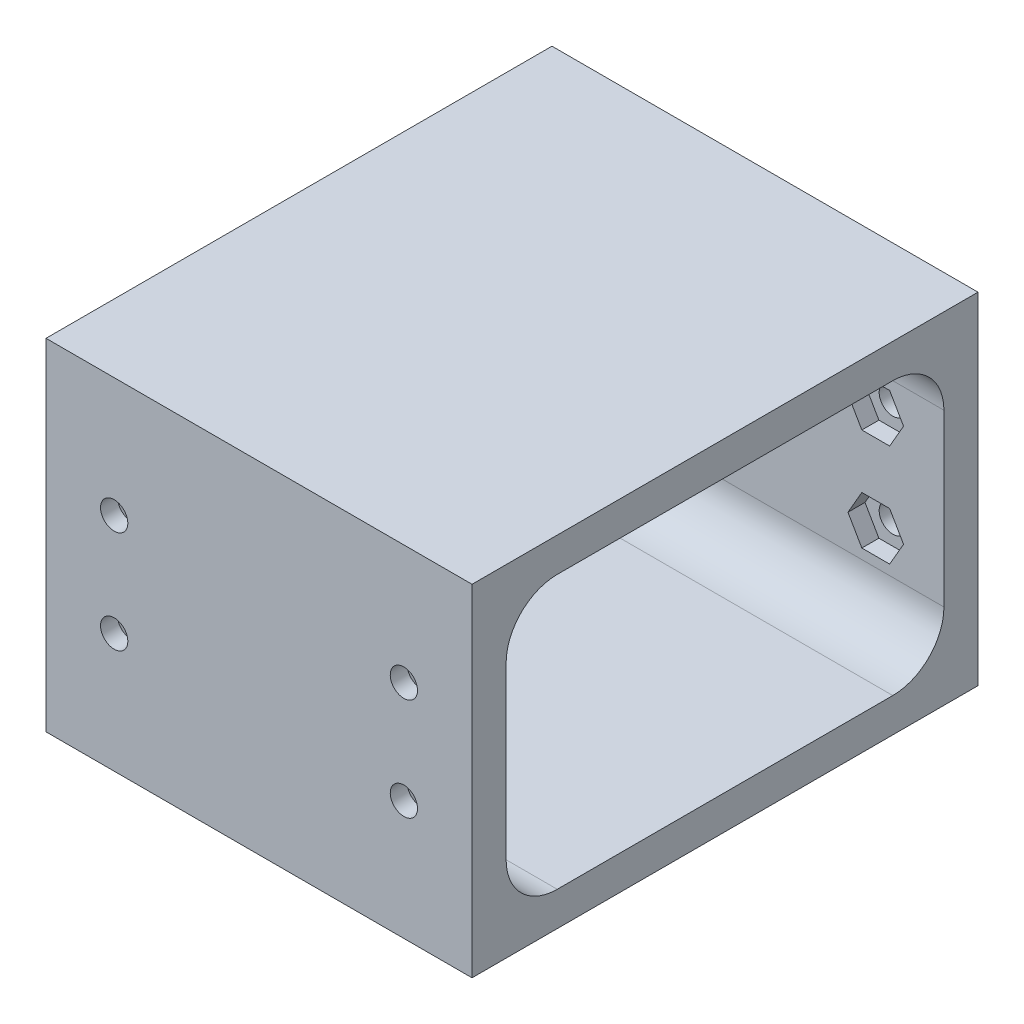
from build123d import *

# Parameters (mm, degrees)
SKETCH1_W               = 50
SKETCH1_H               = 40
BOSS_EXTRUDE1_DEPTH     = 4
SKETCH2_W               = 50
SKETCH2_H               = 4
BOSS_EXTRUDE2_DEPTH     = 55.38
SKETCH4_W               = 50
SKETCH4_H               = 4
BOSS_EXTRUDE3_DEPTH     = 32
SKETCH5_R               = 1.6
CUT_EXTRUDE1_DEPTH      = 1
CUT_EXTRUDE1_DEPTH_BACK = 60.38
CUT_EXTRUDE2_START      = -2
CUT_EXTRUDE2_DEPTH      = 55.38
FILLET1_R               = 6


with BuildPart() as part:
    # Sketch1 → Boss-Extrude1 (new body)
    with BuildSketch(Plane.XY):
        with Locations((-443.882332823, -0.367507575)):
            Rectangle(SKETCH1_W, SKETCH1_H)
    extrude(amount=BOSS_EXTRUDE1_DEPTH)

    # Sketch2 → Boss-Extrude2 (add)
    with BuildSketch(Plane.XY.offset(4)):
        with Locations((-443.882332823, -18.367507575)):
            Rectangle(SKETCH2_W, SKETCH2_H)
        with Locations((-443.882332823, 17.632492425)):
            Rectangle(SKETCH2_W, SKETCH2_H)
    extrude(amount=BOSS_EXTRUDE2_DEPTH)

    # Sketch4 → Boss-Extrude3 (add)
    with BuildSketch(Plane.XZ.offset(-15.632492425)):
        with Locations((-443.882332823, 57.38)):
            Rectangle(SKETCH4_W, SKETCH4_H)
    extrude(amount=BOSS_EXTRUDE3_DEPTH)

    # Sketch5 → Cut-Extrude1 (cut, two sides)
    with BuildSketch(Plane.XY.offset(59.38)) as cut_extrude1_sk:
        with Locations((-460.882332823, -6.367507575)):
            Circle(SKETCH5_R)
        with Locations((-460.882332823, 5.632492425)):
            Circle(SKETCH5_R)
        with Locations((-426.882332823, -6.367507575)):
            Circle(SKETCH5_R)
        with Locations((-426.882332823, 5.632492425)):
            Circle(SKETCH5_R)
    extrude(amount=CUT_EXTRUDE1_DEPTH, mode=Mode.SUBTRACT)
    extrude(cut_extrude1_sk.sketch, amount=-CUT_EXTRUDE1_DEPTH_BACK, mode=Mode.SUBTRACT)

    # Sketch6 → Cut-Extrude2 (cut)
    with BuildSketch(Plane(origin=(0, 0, 55.38), x_dir=(-1, 0, 0), z_dir=(0, 0, -1)).offset(CUT_EXTRUDE2_START)):
        Polygon((457.620303802, 5.632492425), (459.251318313, 2.807492425), (462.513347334, 2.807492425), (464.144361844, 5.632492425), (462.513347334, 8.457492425), (459.251318313, 8.457492425), align=None)
        Polygon((457.620303802, -6.367507575), (459.251318313, -9.192507575), (462.513347334, -9.192507575), (464.144361844, -6.367507575), (462.513347334, -3.542507575), (459.251318313, -3.542507575), align=None)
        Polygon((425.251318313, 2.807492425), (428.513347334, 2.807492425), (430.144361844, 5.632492425), (428.513347334, 8.457492425), (425.251318313, 8.457492425), (423.620303802, 5.632492425), align=None)
        Polygon((423.620303802, -6.367507575), (425.251318313, -9.192507575), (428.513347334, -9.192507575), (430.144361844, -6.367507575), (428.513347334, -3.542507575), (425.251318313, -3.542507575), align=None)
    extrude(amount=CUT_EXTRUDE2_DEPTH, mode=Mode.SUBTRACT)

    # Fillet1
    fillet1_edges = [part.edges().sort_by_distance(p)[0] for p in [
        (-443.882332823, -16.367507575, 4),
        (-443.882332823, 15.632492425, 4),
        (-443.882332823, 15.632492425, 55.38),
        (-443.882332823, -16.367507575, 55.38),
    ]]
    fillet(fillet1_edges, radius=FILLET1_R)


solid = part.part
